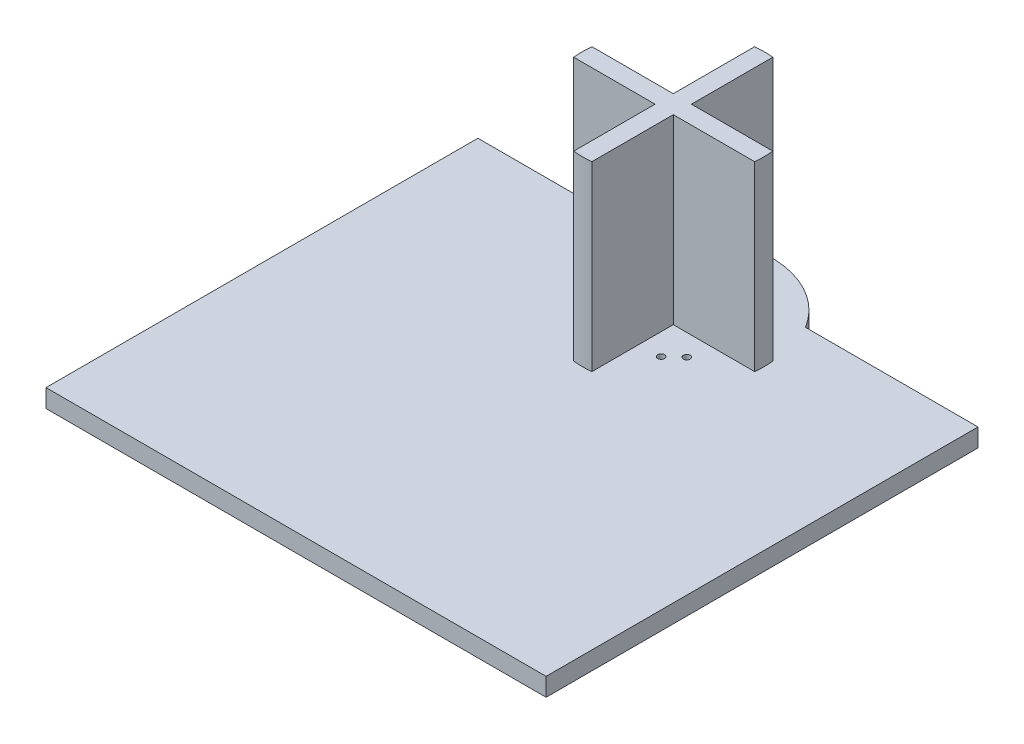
from build123d import *

# Parameters (mm, degrees)
BOSS_EXTRUDE4_DEPTH = 4
SKETCH3_R           = 20
BOSS_EXTRUDE5_DEPTH = 40
SKETCH4_W           = 38.356352869
SKETCH4_H           = 36.352662793
SKETCH4_W_2         = 41.648129421
SKETCH4_H_2         = 27.192936736
SKETCH4_W_3         = 57.677650023
SKETCH4_H_3         = 26.910385372
SKETCH4_W_4         = 38.070111429
SKETCH4_H_4         = 39.361887981
CUT_EXTRUDE5_DEPTH  = 40
SKETCH7_R           = 0.75
CUT_EXTRUDE6_DEPTH  = 5


with BuildPart() as part:
    # Sketch2 → Boss-Extrude4 (new body)
    with BuildSketch(Plane(origin=(0, 0, 0), x_dir=(1, 0, 0), z_dir=(0, 1, 0))):
        with BuildLine():
            Line((0, 95), (0, 0))
            Line((0, 0), (110, 0))
            Line((110, 0), (110, 95))
            Line((110, 95), (72.04868569, 95))
            ThreePointArc((72.04868569, 95), (55, 104.543312367), (37.95131431, 95))
            Line((37.95131431, 95), (0, 95))
        make_face()
    extrude(amount=BOSS_EXTRUDE4_DEPTH)

    # Sketch3 → Boss-Extrude5 (add)
    with BuildSketch(Plane(origin=(0, 4, 0), x_dir=(1, 0, 0), z_dir=(0, 1, 0))):
        with Locations((55, 82.97105055)):
            Circle(SKETCH3_R)
    extrude(amount=BOSS_EXTRUDE5_DEPTH)

    # Sketch4 → Cut-Extrude5 (cut)
    with BuildSketch(Plane(origin=(0, 44, 0), x_dir=(1, 0, 0), z_dir=(0, 1, 0))):
        with Locations((33.821823565, 62.794719153)):
            Rectangle(SKETCH4_W, SKETCH4_H)
        with Locations((32.17593529, 98.567518918)):
            Rectangle(SKETCH4_W_2, SKETCH4_H_2)
        with Locations((85.838825012, 98.426243236)):
            Rectangle(SKETCH4_W_3, SKETCH4_H_3)
        with Locations((76.035055715, 61.29010656)):
            Rectangle(SKETCH4_W_4, SKETCH4_H_4)
    extrude(amount=-CUT_EXTRUDE5_DEPTH, mode=Mode.SUBTRACT)

    # Sketch7 → Cut-Extrude6 (cut, through all)
    with BuildSketch(Plane(origin=(0, 4, 0), x_dir=(1, 0, 0), z_dir=(0, 1, 0))):
        with Locations((45.324714989, 89.67105055)):
            Circle(SKETCH7_R)
        with Locations((48.261379546, 92.386930017)):
            Circle(SKETCH7_R)
        with Locations((61.738620454, 92.386930017)):
            Circle(SKETCH7_R)
        with Locations((64.675285011, 89.67105055)):
            Circle(SKETCH7_R)
        with Locations((64.675285011, 76.27105055)):
            Circle(SKETCH7_R)
        with Locations((61.738620454, 73.555171083)):
            Circle(SKETCH7_R)
        with Locations((48.261379546, 73.555171083)):
            Circle(SKETCH7_R)
        with Locations((45.324714989, 76.27105055)):
            Circle(SKETCH7_R)
    extrude(amount=-CUT_EXTRUDE6_DEPTH, mode=Mode.SUBTRACT)


solid = part.part
